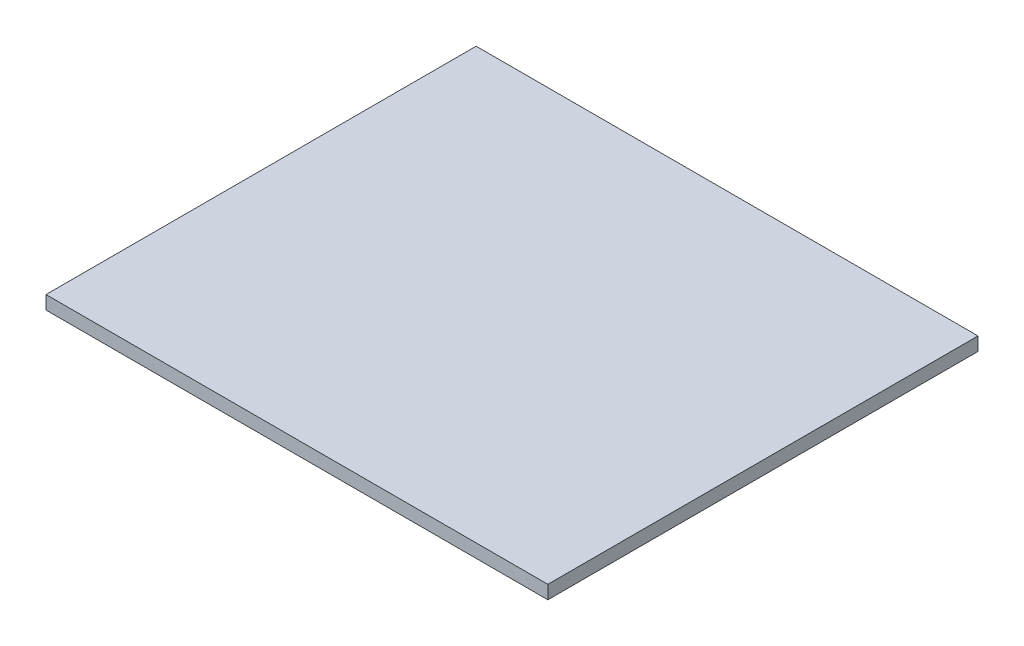
from build123d import *

# Parameters (mm, degrees)
SKETCH1_W           = 711.2
SKETCH1_H           = 609.6
BOSS_EXTRUDE1_DEPTH = 19.05


with BuildPart() as part:
    # Sketch1 → Boss-Extrude1 (new body)
    with BuildSketch(Plane(origin=(0, 0, 0), x_dir=(1, 0, 0), z_dir=(0, 1, 0))):
        Rectangle(SKETCH1_W, SKETCH1_H)
    extrude(amount=BOSS_EXTRUDE1_DEPTH)


solid = part.part
